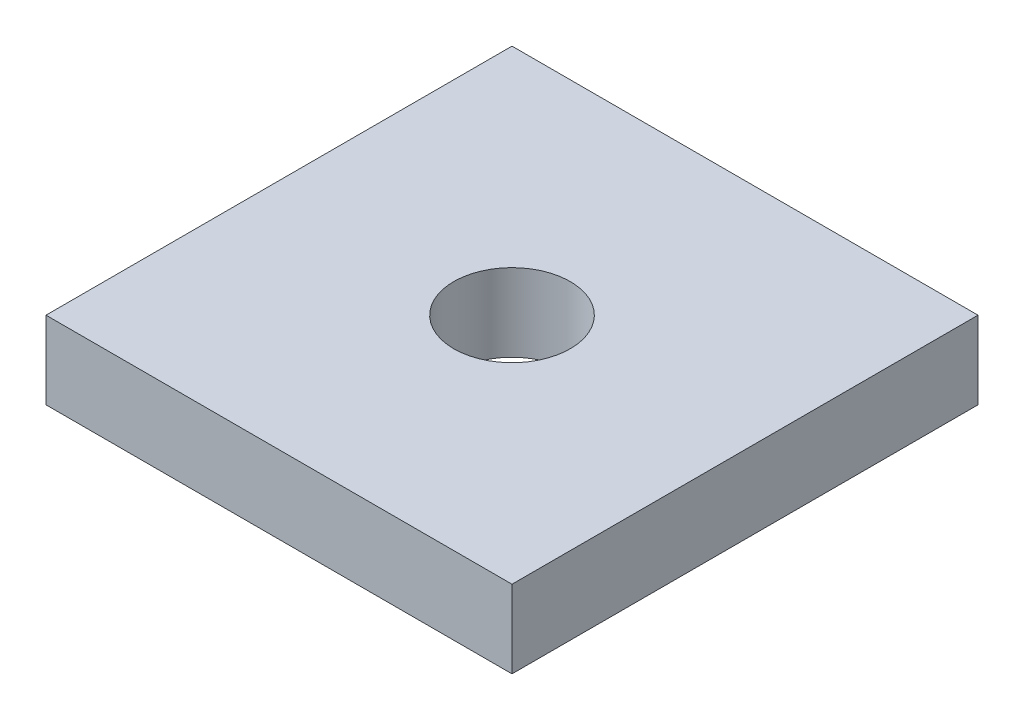
from build123d import *

# Parameters (mm, degrees)
SKETCH1_W           = 76.2
SKETCH1_H           = 76.2
SKETCH1_R           = 9.525
BOSS_EXTRUDE1_DEPTH = 12.7


with BuildPart() as part:
    # Sketch1 → Boss-Extrude1 (new body)
    with BuildSketch(Plane(origin=(0, 0, 0), x_dir=(1, 0, 0), z_dir=(0, 1, 0))):
        with Locations((38.1, 38.1)):
            Rectangle(SKETCH1_W, SKETCH1_H)
        with Locations((38.1, 38.1)):
            Circle(SKETCH1_R, mode=Mode.SUBTRACT)
    extrude(amount=BOSS_EXTRUDE1_DEPTH)


solid = part.part
